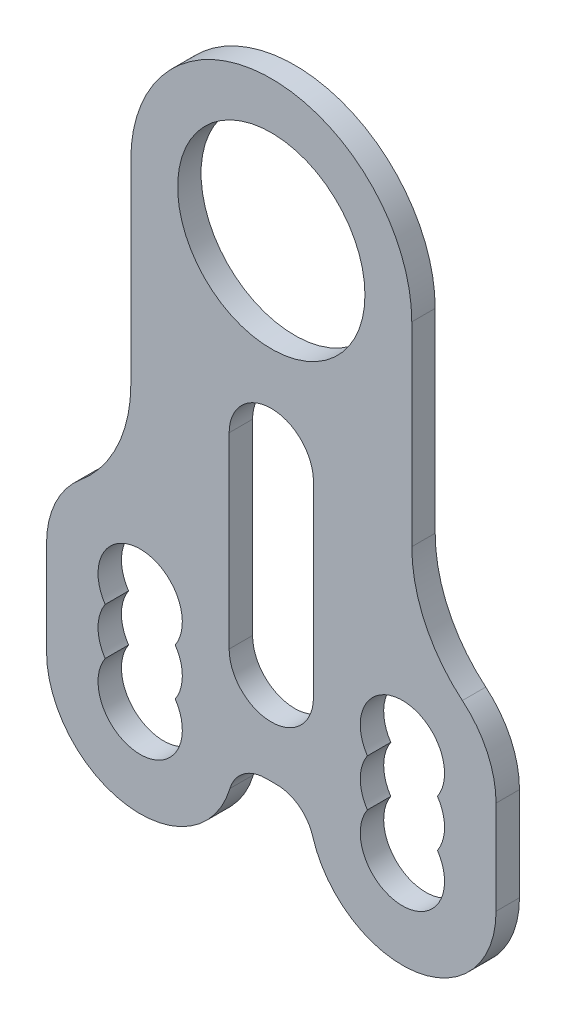
from build123d import *

# Parameters (mm, degrees)
SKETCH_1_R      = 10
EXTRUDE_1_DEPTH = 2.5


with BuildPart() as part:
    # 草图1 → 凸台-拉伸1 (new body)
    with BuildSketch(Plane.XY):
        with BuildLine():
            Line((-24, -40), (-24, -50))
            ThreePointArc((-24, -50), (-15.443695821, -59.895238369), (-4.416851525, -52.857142857))
            ThreePointArc((-4.416851525, -52.857142857), (-2.974049354, -50.792865097), (-0.583592135, -50))
            Line((-0.583592135, -50), (0.583592135, -50))
            ThreePointArc((0.583592135, -50), (2.974049354, -50.792865097), (4.416851525, -52.857142857))
            ThreePointArc((4.416851525, -52.857142857), (15.443695821, -59.895238369), (24, -50))
            Line((24, -50), (24, -40))
            ThreePointArc((24, -40), (23.055385138, -35.757359313), (20.4, -32.316250915))
            ThreePointArc((20.4, -32.316250915), (16.416922293, -27.154588318), (15, -20.790627288))
            Line((15, -20.790627288), (15, 0))
            ThreePointArc((15, 0), (0, 15), (-15, 0))
            Line((-15, 0), (-15, -20.790627288))
            ThreePointArc((-15, -20.790627288), (-16.416922293, -27.154588318), (-20.4, -32.316250915))
            ThreePointArc((-20.4, -32.316250915), (-23.055385138, -35.757359313), (-24, -40))
        make_face()
        Circle(SKETCH_1_R, mode=Mode.SUBTRACT)
        with BuildLine():
            Line((-4.5, -20), (-4.5, -40))
            ThreePointArc((-4.5, -40), (0, -44.5), (4.5, -40))
            Line((4.5, -40), (4.5, -20))
            ThreePointArc((4.5, -20), (0, -15.5), (-4.5, -20))
        make_face(mode=Mode.SUBTRACT)
        with BuildLine():
            ThreePointArc((-17.741657387, -47.5), (-14, -54.5), (-10.258342613, -47.5))
            ThreePointArc((-10.258342613, -47.5), (-9.5, -45), (-10.258342613, -42.5))
            ThreePointArc((-10.258342613, -42.5), (-14, -35.5), (-17.741657387, -42.5))
            ThreePointArc((-17.741657387, -42.5), (-18.5, -45), (-17.741657387, -47.5))
        make_face(mode=Mode.SUBTRACT)
        with BuildLine():
            ThreePointArc((10.258342613, -47.5), (9.5, -45), (10.258342613, -42.5))
            ThreePointArc((10.258342613, -42.5), (14, -35.5), (17.741657387, -42.5))
            ThreePointArc((17.741657387, -42.5), (18.5, -45), (17.741657387, -47.5))
            ThreePointArc((17.741657387, -47.5), (14, -54.5), (10.258342613, -47.5))
        make_face(mode=Mode.SUBTRACT)
    extrude(amount=EXTRUDE_1_DEPTH)


solid = part.part
